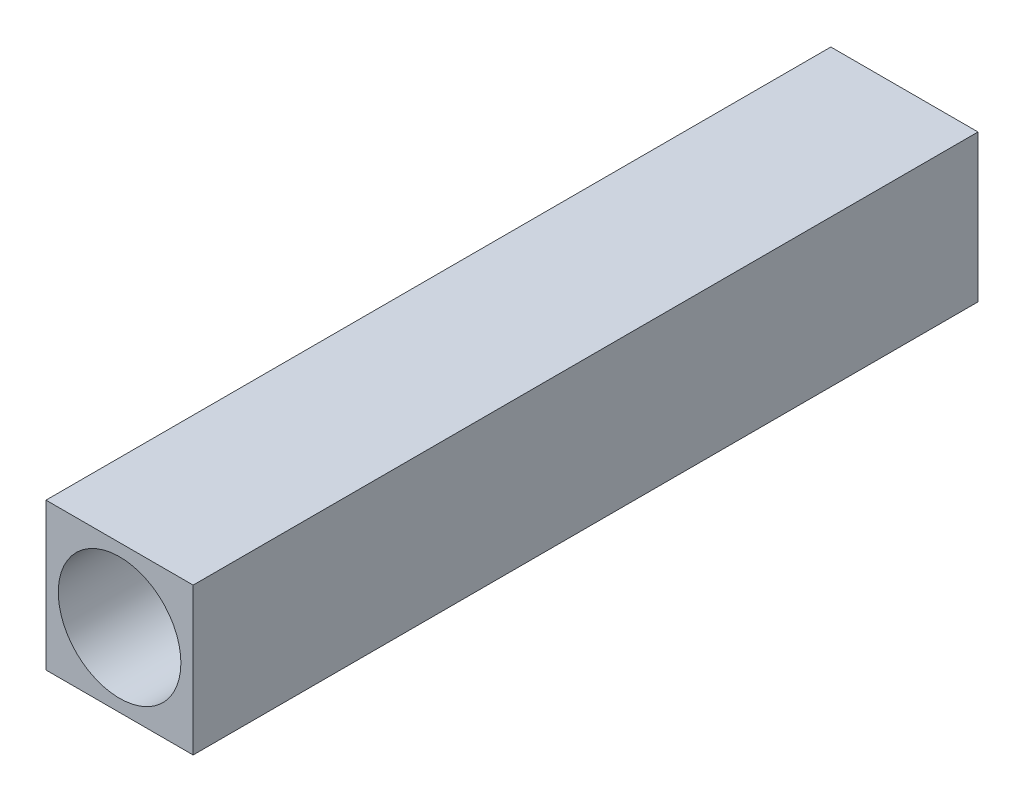
from build123d import *

# Parameters (mm, degrees)
SKETCH1_W           = 76.2
SKETCH1_H           = 76.2
SKETCH1_R           = 31.75
BOSS_EXTRUDE1_DEPTH = 406.4
CUT_EXTRUDE1_START  = 406.4
SKETCH1_3_R         = 31.75
CUT_EXTRUDE1_DEPTH  = 304.8


with BuildPart() as part:
    # Sketch1 → Boss-Extrude1 (new body)
    with BuildSketch(Plane.XY):
        Rectangle(SKETCH1_W, SKETCH1_H)
        Circle(SKETCH1_R, mode=Mode.SUBTRACT)
        Circle(SKETCH1_R)
    extrude(amount=BOSS_EXTRUDE1_DEPTH)

    # Sketch1_3 → Cut-Extrude1 (cut)
    with BuildSketch(Plane.XY.offset(CUT_EXTRUDE1_START)):
        Circle(SKETCH1_3_R)
    extrude(amount=-CUT_EXTRUDE1_DEPTH, mode=Mode.SUBTRACT)


solid = part.part
